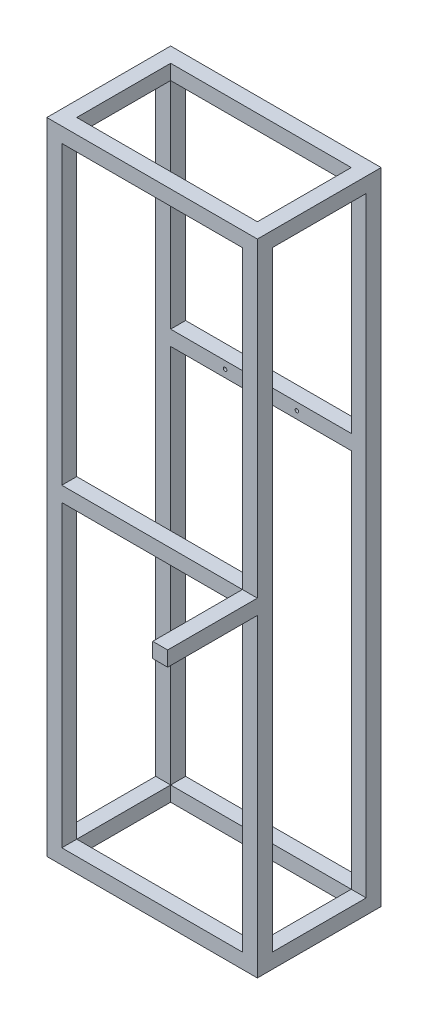
from build123d import *

# Parameters (mm, degrees)
SKETCH_1_W          = 352
SKETCH_1_H          = 207
SKETCH_1_W_2        = 302
SKETCH_1_H_2        = 157
EXTRUDE_1_DEPTH     = 25
SKETCH_2_W          = 25
SKETCH_2_H          = 25
EXTRUDE_2_DEPTH     = 1045
SKETCH_3_W          = 352
SKETCH_3_H          = 207
SKETCH_3_W_2        = 302
SKETCH_3_H_2        = 157
EXTRUDE_3_DEPTH     = 25
EXTRUDE_START       = -25
SKETCH_4_W          = 302
SKETCH_4_H          = 25
EXTRUDE_4_DEPTH     = 25
SKETCH_5_W          = 302
SKETCH_5_H          = 25
EXTRUDE_5_DEPTH     = 25
SKETCH_6_W          = 25
SKETCH_6_H          = 25
EXTRUDE_6_DEPTH     = 150
CUT_EXTRUDE_1_REACH = 359
SKETCH_7_R          = 3


with BuildPart() as part:
    # Эскиз1 → Бобышка-Вытянуть1 (new body)
    with BuildSketch(Plane(origin=(0, 0, 0), x_dir=(1, 0, 0), z_dir=(0, 1, 0))):
        with Locations((176, 103.5)):
            Rectangle(SKETCH_1_W, SKETCH_1_H)
        with Locations((176, 103.5)):
            Rectangle(SKETCH_1_W_2, SKETCH_1_H_2, mode=Mode.SUBTRACT)
    extrude(amount=EXTRUDE_1_DEPTH)

    # Эскиз2 → Бобышка-Вытянуть2 (add)
    with BuildSketch(Plane(origin=(0, 25, 0), x_dir=(1, 0, 0), z_dir=(0, 1, 0))):
        with Locations((12.5, 194.5)):
            Rectangle(SKETCH_2_W, SKETCH_2_H)
        with Locations((12.5, 12.5)):
            Rectangle(SKETCH_2_W, SKETCH_2_H)
        with Locations((339.5, 12.5)):
            Rectangle(SKETCH_2_W, SKETCH_2_H)
        with Locations((339.5, 194.5)):
            Rectangle(SKETCH_2_W, SKETCH_2_H)
    extrude(amount=EXTRUDE_2_DEPTH)

    # Эскиз3 → Бобышка-Вытянуть3 (add)
    with BuildSketch(Plane(origin=(0, 1070, 0), x_dir=(1, 0, 0), z_dir=(0, 1, 0))):
        with Locations((176, 103.5)):
            Rectangle(SKETCH_3_W, SKETCH_3_H)
        with Locations((176, 103.5)):
            Rectangle(SKETCH_3_W_2, SKETCH_3_H_2, mode=Mode.SUBTRACT)
    extrude(amount=-EXTRUDE_3_DEPTH)

    # Эскиз4 → Бобышка-Вытянуть4 (add)
    with BuildSketch(Plane(origin=(0, 0, -207), x_dir=(-1, 0, 0), z_dir=(0, 0, -1)).offset(EXTRUDE_START)):
        with Locations((-176, 672.5)):
            Rectangle(SKETCH_4_W, SKETCH_4_H)
    extrude(amount=EXTRUDE_4_DEPTH)

    # Эскиз5 → Бобышка-Вытянуть5 (add)
    with BuildSketch(Plane.XY.offset(EXTRUDE_START)):
        with Locations((176, 537.5)):
            Rectangle(SKETCH_5_W, SKETCH_5_H)
    extrude(amount=EXTRUDE_5_DEPTH)

    # Эскиз6 → Бобышка-Вытянуть6 (add)
    with BuildSketch(Plane.XY):
        with Locations((339.5, 537.5)):
            Rectangle(SKETCH_6_W, SKETCH_6_H)
    extrude(amount=EXTRUDE_6_DEPTH)

    # Эскиз7 → Вырез-Вытянуть1 (cut, up to next)
    with BuildSketch(Plane(origin=(0, 0, -207), x_dir=(-1, 0, 0), z_dir=(0, 0, -1)), mode=Mode.PRIVATE) as cut_extrude_1_sk1:
        with Locations((-236, 672.5)):
            Circle(SKETCH_7_R)
    cut_extrude_1_tool1 = extrude(cut_extrude_1_sk1.sketch, amount=-CUT_EXTRUDE_1_REACH, mode=Mode.PRIVATE) & part.part
    add(cut_extrude_1_tool1.solids().sort_by_distance((236, 672.5, -207))[0], mode=Mode.SUBTRACT)
    # Эскиз7 → Вырез-Вытянуть1 (cut, up to next)
    with BuildSketch(Plane(origin=(0, 0, -207), x_dir=(-1, 0, 0), z_dir=(0, 0, -1)), mode=Mode.PRIVATE) as cut_extrude_1_sk2:
        with Locations((-116, 672.5)):
            Circle(SKETCH_7_R)
    cut_extrude_1_tool2 = extrude(cut_extrude_1_sk2.sketch, amount=-CUT_EXTRUDE_1_REACH, mode=Mode.PRIVATE) & part.part
    add(cut_extrude_1_tool2.solids().sort_by_distance((116, 672.5, -207))[0], mode=Mode.SUBTRACT)


solid = part.part
